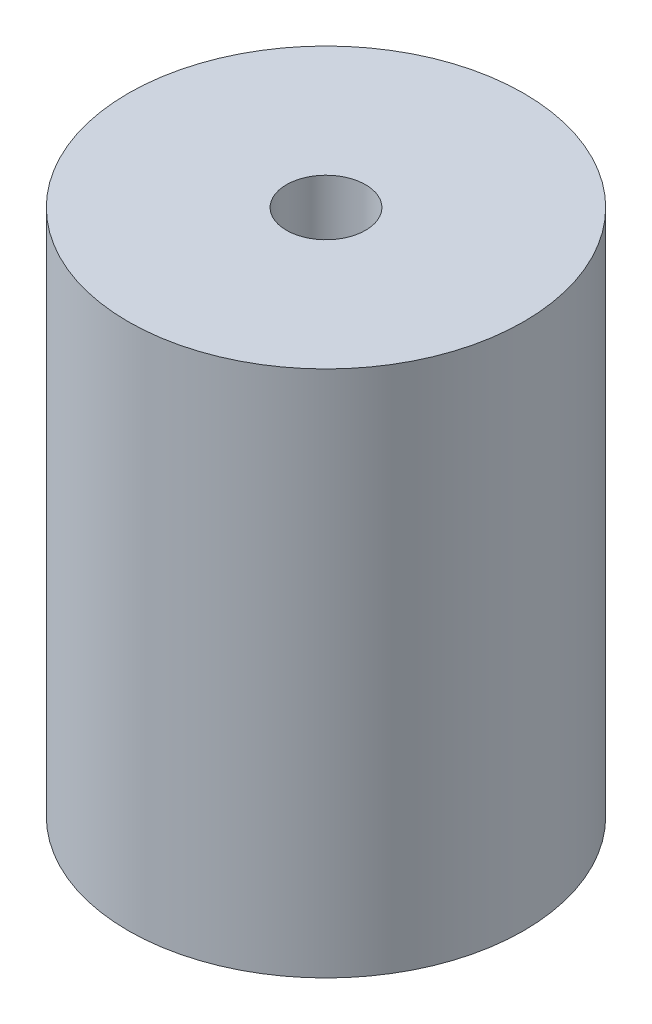
from build123d import *

# Parameters (mm, degrees)
SKETCH1_R           = 15
BOSS_EXTRUDE1_DEPTH = 40
SKETCH2_R           = 3
CUT_EXTRUDE1_DEPTH  = 20
SKETCH3_R           = 4
CUT_EXTRUDE2_DEPTH  = 20


with BuildPart() as part:
    # Sketch1 → Boss-Extrude1 (new body)
    with BuildSketch(Plane(origin=(0, 0, 0), x_dir=(1, 0, 0), z_dir=(0, 1, 0))):
        Circle(SKETCH1_R)
    extrude(amount=BOSS_EXTRUDE1_DEPTH)

    # Sketch2 → Cut-Extrude1 (cut)
    with BuildSketch(Plane(origin=(0, 40, 0), x_dir=(1, 0, 0), z_dir=(0, 1, 0))):
        Circle(SKETCH2_R)
    extrude(amount=-CUT_EXTRUDE1_DEPTH, mode=Mode.SUBTRACT)

    # Sketch3 → Cut-Extrude2 (cut)
    with BuildSketch(Plane.XZ):
        Circle(SKETCH3_R)
    extrude(amount=-CUT_EXTRUDE2_DEPTH, mode=Mode.SUBTRACT)


solid = part.part
